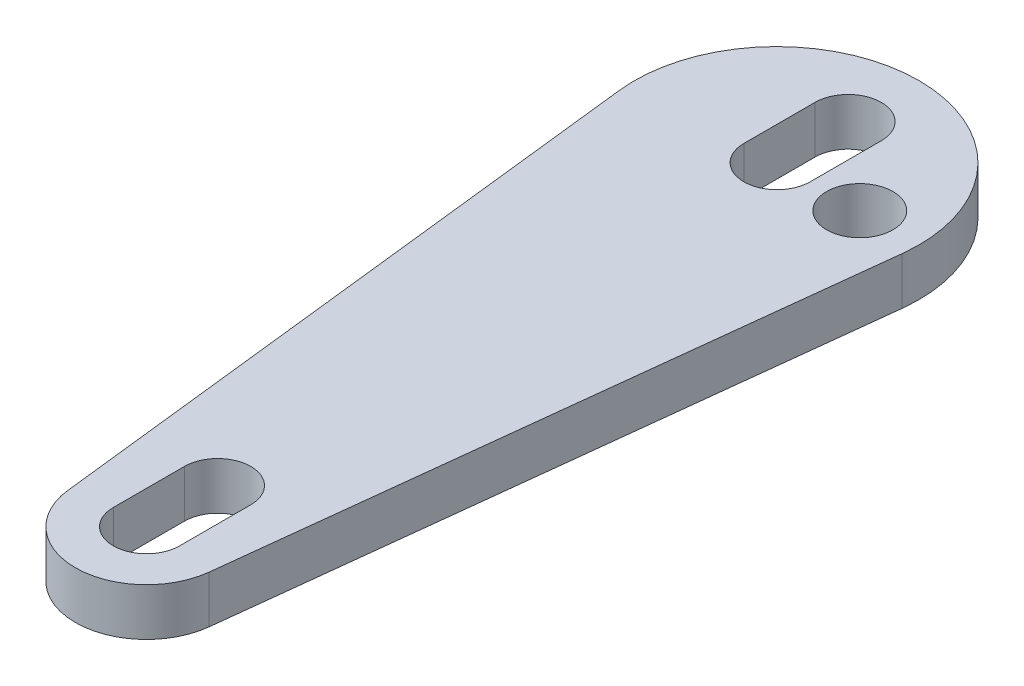
from build123d import *

# Parameters (mm, degrees)
SKETCH1_R           = 1.4
BOSS_EXTRUDE1_DEPTH = 2


with BuildPart() as part:
    # Sketch1 → Boss-Extrude1 (new body)
    with BuildSketch(Plane(origin=(0, 0, 0), x_dir=(1, 0, 0), z_dir=(0, 1, 0))):
        with BuildLine():
            Line((-5.961660753, 25.902799097), (-2.980830377, -0.338600451))
            ThreePointArc((-2.980830377, -0.338600451), (0, -3), (2.980830377, -0.338600451))
            Line((2.980830377, -0.338600451), (5.961660753, 25.902799097))
            ThreePointArc((5.961660753, 25.902799097), (0, 32.58), (-5.961660753, 25.902799097))
        make_face()
        with Locations((3.5, 26.58)):
            Circle(SKETCH1_R, mode=Mode.SUBTRACT)
        with BuildLine():
            Line((-1.4, 0), (-1.4, 3))
            ThreePointArc((-1.4, 3), (0, 4.4), (1.4, 3))
            Line((1.4, 3), (1.4, 0))
            ThreePointArc((1.4, 0), (0, -1.4), (-1.4, 0))
        make_face(mode=Mode.SUBTRACT)
        with BuildLine():
            Line((1.4, 29.59), (1.4, 26.59))
            ThreePointArc((1.4, 26.59), (0, 25.19), (-1.4, 26.59))
            Line((-1.4, 26.59), (-1.4, 29.59))
            ThreePointArc((-1.4, 29.59), (0, 30.99), (1.4, 29.59))
        make_face(mode=Mode.SUBTRACT)
    extrude(amount=BOSS_EXTRUDE1_DEPTH)


solid = part.part
